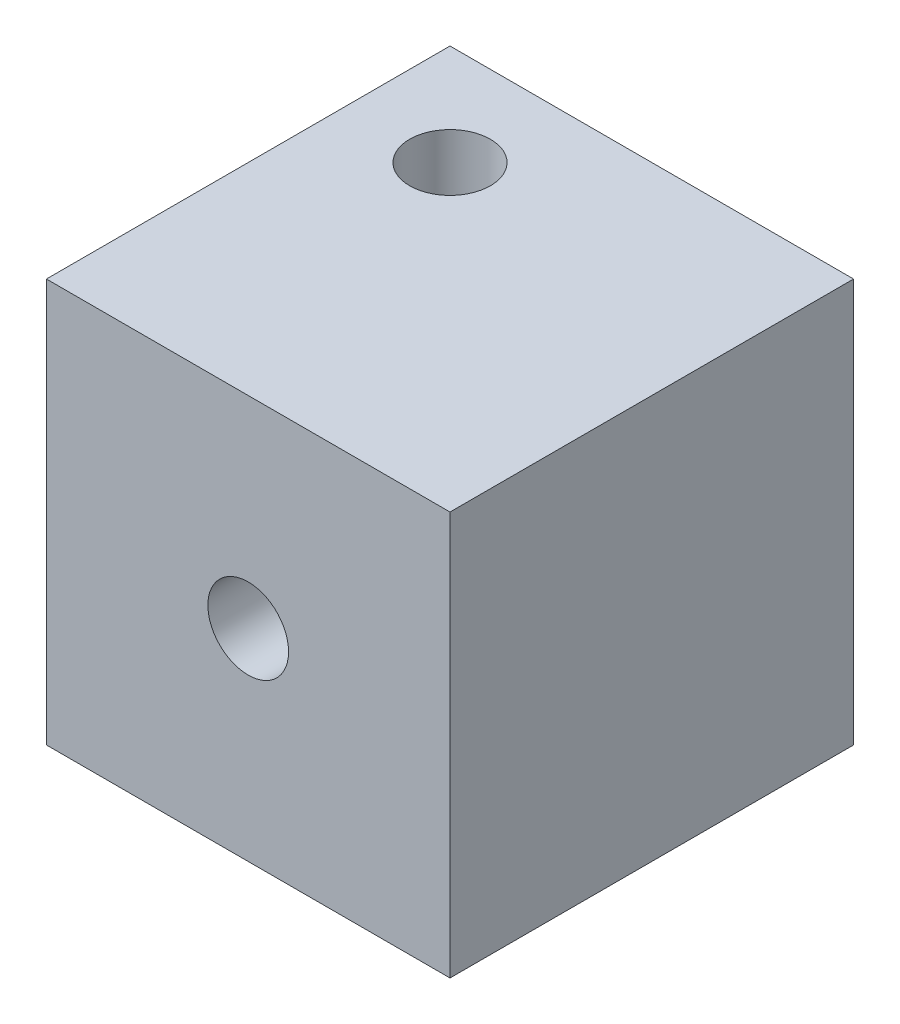
from build123d import *

# Parameters (mm, degrees)
ESQUISSE2_W             = 100
ESQUISSE2_H             = 100
BOSS_EXTRU_1_DEPTH      = 100
ESQUISSE3_R             = 10
ENL_V_MAT_EXTRU_1_DEPTH = 101
ESQUISSE4_R             = 10
ENL_V_MAT_EXTRU_2_DEPTH = 101


with BuildPart() as part:
    # Esquisse2 → Boss.-Extru.1 (new body)
    with BuildSketch(Plane.XY):
        with Locations((-50, 50)):
            Rectangle(ESQUISSE2_W, ESQUISSE2_H)
    extrude(amount=BOSS_EXTRU_1_DEPTH)

    # Esquisse3 → Enlèv. mat.-Extru.1 (cut, through all)
    with BuildSketch(Plane.XY.offset(100)):
        with Locations((-50, 50)):
            Circle(ESQUISSE3_R)
    extrude(amount=-ENL_V_MAT_EXTRU_1_DEPTH, mode=Mode.SUBTRACT)

    # Esquisse4 → Enlèv. mat.-Extru.2 (cut, through all)
    with BuildSketch(Plane(origin=(0, 100, 0), x_dir=(1, 0, 0), z_dir=(0, 1, 0))):
        with Locations((-75, -25)):
            Circle(ESQUISSE4_R)
    extrude(amount=-ENL_V_MAT_EXTRU_2_DEPTH, mode=Mode.SUBTRACT)


solid = part.part
